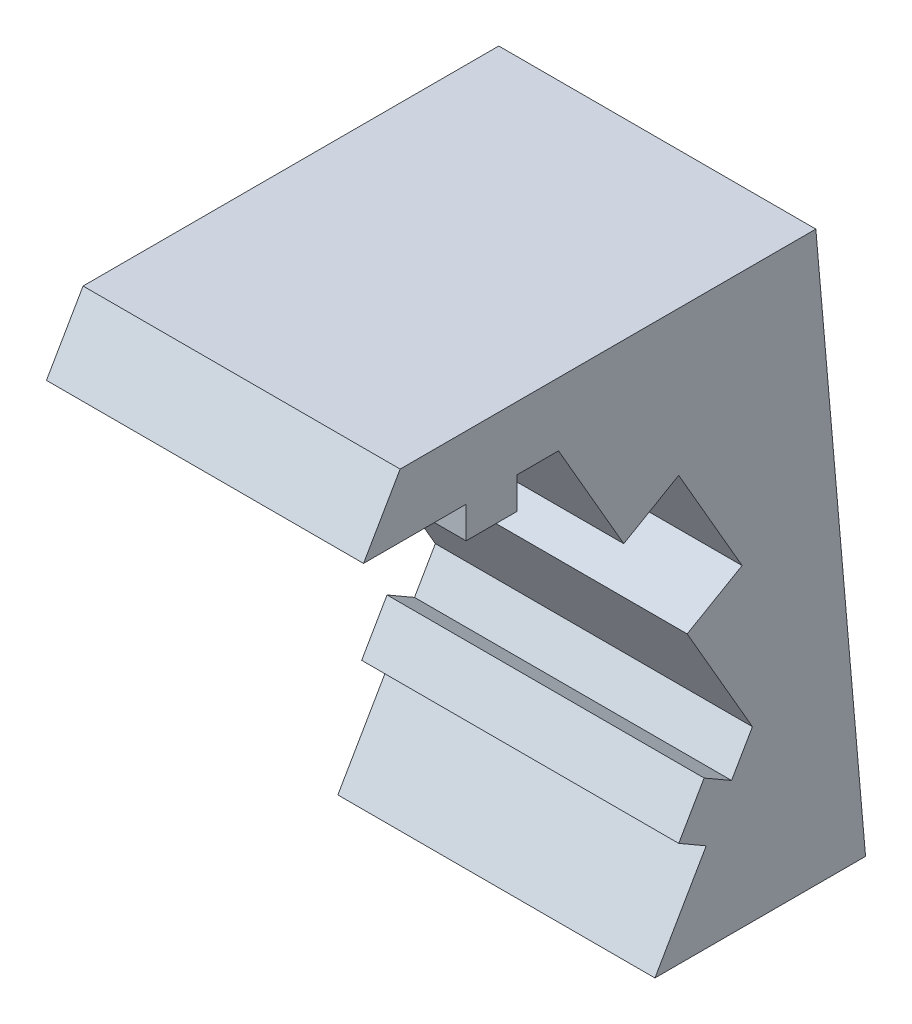
from build123d import *

# Parameters (mm, degrees)
BOSS_EXTRUDE1_DEPTH = 10


with BuildPart() as part:
    # Sketch1 → Boss-Extrude1 (new body)
    with BuildSketch(Plane(origin=(50.25, 0, 0), x_dir=(0, 0, -1), z_dir=(1, 0, 0))):
        Polygon((8.173205081, 7.02820323), (6.115470054, 10.592304845), (4.8, 10.592304845), (4.8, 9.592304845), (3.2, 9.592304845), (3.2, 10.592304845), (-0.034272207, 10.592304845), (1.120428331, 12.592304845), (14.230940108, 12.592304845), (15.798574043, -5.325833025), (14.230940108, -5.325833025), (9.156068977, -5.325833025), (10.773205081, -2.524871131), (9.907179677, -2.024871131), (10.707179677, -0.639230485), (11.573205081, -1.139230485), (12.230940108, 0), (10.173205081, 3.564101615), (11.905255888, 4.564101615), (9.905255888, 8.02820323), align=None)
    extrude(amount=-BOSS_EXTRUDE1_DEPTH)


solid = part.part
